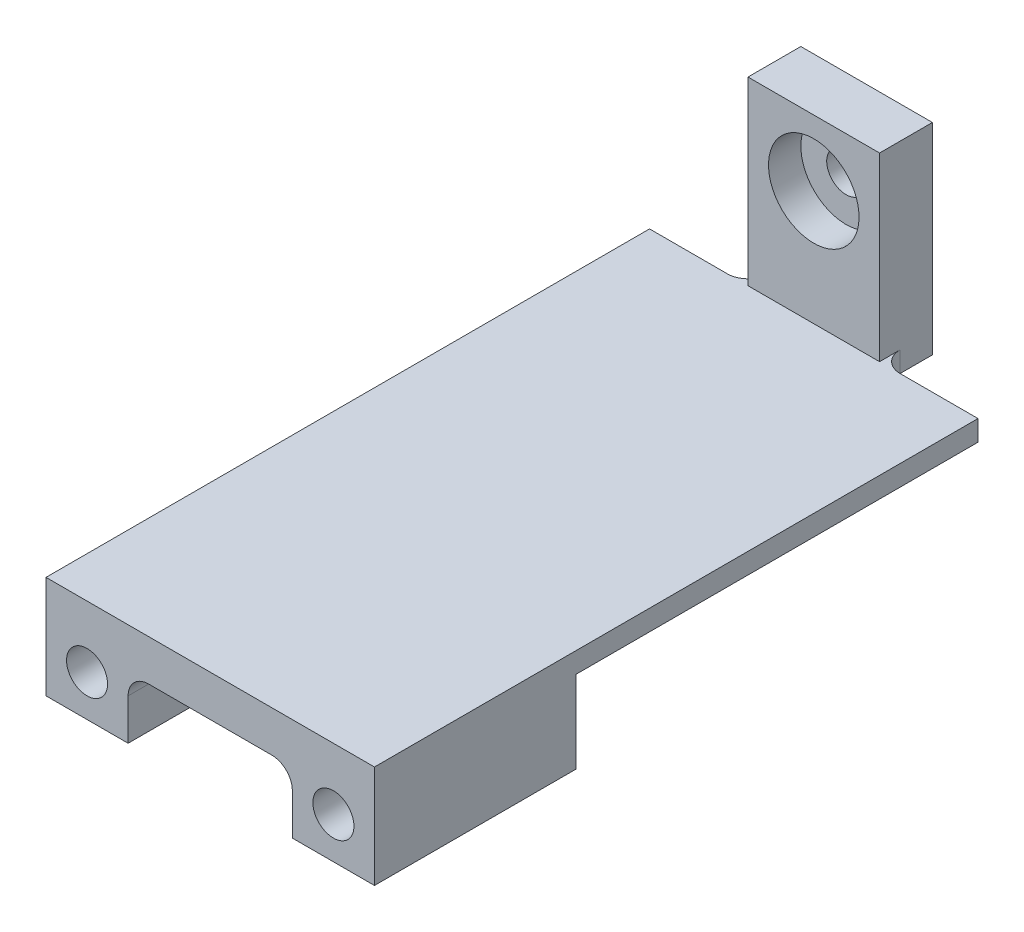
from build123d import *

# Parameters (mm, degrees)
SKETCH1_W               = 177.8
SKETCH1_H               = 101.6
BOSS_EXTRUDE1_DEPTH     = 12.7
SKETCH2_W               = 25.4
SKETCH2_H               = 19.05
BOSS_EXTRUDE2_DEPTH     = 101.6
SKETCH3_R               = 6.35
CUT_EXTRUDE1_DEPTH      = 101.6
SKETCH4_W               = 25.4
SKETCH4_H               = 19.05
BOSS_EXTRUDE3_DEPTH     = 101.6
SKETCH5_R               = 6.35
CUT_EXTRUDE2_DEPTH      = 101.6
SKETCH6_W               = 76.2
SKETCH6_H               = 31.75
CUT_EXTRUDE3_DEPTH      = 101.6
FILLET1_R               = 6.35
SKETCH8_W               = 101.6
SKETCH8_H               = 12.7
BOSS_EXTRUDE5_DEPTH     = 85.09
SKETCH9_W               = 40.7
SKETCH9_H               = 68.61
SKETCH9_R               = 6
BOSS_EXTRUDE6_DEPTH     = 16.35
SKETCH10_R              = 14
CUT_EXTRUDE4_DEPTH      = 10
FILLET2_R               = 6.35
SKETCH11_W              = 105.926535366
SKETCH11_H              = 109.219193109
CUT_EXTRUDE5_DEPTH      = 6.35
FILLET3_R               = 3.175
SKETCH12_W              = 101.6
SKETCH12_H              = 25.4
CUT_EXTRUDE6_DEPTH      = 3.175
CUT_EXTRUDE6_DEPTH_BACK = 39.25


with BuildPart() as part:
    # Sketch1 → Boss-Extrude1 (new body)
    with BuildSketch(Plane(origin=(0, 0, 0), x_dir=(1, 0, 0), z_dir=(0, 1, 0))):
        Rectangle(SKETCH1_W, SKETCH1_H)
    extrude(amount=BOSS_EXTRUDE1_DEPTH)

    # Sketch2 → Boss-Extrude2 (add)
    with BuildSketch(Plane.XY.offset(50.8)):
        with Locations((0, -9.525)):
            Rectangle(SKETCH2_W, SKETCH2_H)
    extrude(amount=-BOSS_EXTRUDE2_DEPTH)

    # Sketch3 → Cut-Extrude1 (cut)
    with BuildSketch(Plane.XY.offset(50.8)):
        with Locations((0, -6.35)):
            Circle(SKETCH3_R)
    extrude(amount=-CUT_EXTRUDE1_DEPTH, mode=Mode.SUBTRACT)

    # Sketch4 → Boss-Extrude3 (add)
    with BuildSketch(Plane.XY.offset(50.8)):
        with Locations((-76.2, -9.525)):
            Rectangle(SKETCH4_W, SKETCH4_H)
    boss_extrude3 = extrude(amount=-BOSS_EXTRUDE3_DEPTH)

    # Mirror1: Boss-Extrude3 across plane
    add(boss_extrude3.mirror(Plane(origin=(0, 0, 0), x_dir=(0, 0, 1), z_dir=(1, 0, 0))))

    # Sketch5 → Cut-Extrude2 (cut)
    with BuildSketch(Plane.XY.offset(50.8)):
        with Locations((-76.2, -6.35)):
            Circle(SKETCH5_R)
        with Locations((76.2, -6.35)):
            Circle(SKETCH5_R)
    extrude(amount=-CUT_EXTRUDE2_DEPTH, mode=Mode.SUBTRACT)

    # Sketch6 → Cut-Extrude3 (cut)
    with BuildSketch(Plane(origin=(0, 0, -50.8), x_dir=(-1, 0, 0), z_dir=(0, 0, -1))):
        with Locations((50.8, -3.175)):
            Rectangle(SKETCH6_W, SKETCH6_H)
    extrude(amount=-CUT_EXTRUDE3_DEPTH, mode=Mode.SUBTRACT)

    # Fillet1
    fillet1_edges = [part.edges().sort_by_distance(p)[0] for p in [
        (12.7, 0, 0),
        (63.5, 0, 0),
    ]]
    fillet(fillet1_edges, radius=FILLET1_R)

    # Sketch8 → Boss-Extrude5 (add)
    with BuildSketch(Plane(origin=(0, 0, -50.8), x_dir=(-1, 0, 0), z_dir=(0, 0, -1))):
        with Locations((-38.1, 6.35)):
            Rectangle(SKETCH8_W, SKETCH8_H)
    extrude(amount=BOSS_EXTRUDE5_DEPTH)

    # Sketch9 → Boss-Extrude6 (add)
    with BuildSketch(Plane(origin=(0, 0, -135.89), x_dir=(-1, 0, 0), z_dir=(0, 0, -1))):
        with Locations((-38.1, 34.305)):
            Rectangle(SKETCH9_W, SKETCH9_H)
        with Locations((-38.1, 48.26)):
            Circle(SKETCH9_R, mode=Mode.SUBTRACT)
    extrude(amount=BOSS_EXTRUDE6_DEPTH)

    # Sketch10 → Cut-Extrude4 (cut)
    with BuildSketch(Plane.XY.offset(-135.89)):
        with Locations((38.1, 48.26)):
            Circle(SKETCH10_R)
    extrude(amount=-CUT_EXTRUDE4_DEPTH, mode=Mode.SUBTRACT)

    # Fillet2
    fillet2_edges = [part.edges().sort_by_distance(p)[0] for p in [
        (58.45, 6.35, -135.89),
        (17.75, 6.35, -135.89),
    ]]
    fillet(fillet2_edges, radius=FILLET2_R)

    # Sketch11 → Cut-Extrude5 (cut)
    with BuildSketch(Plane.XZ):
        with Locations((35.936732317, -105.409596555)):
            Rectangle(SKETCH11_W, SKETCH11_H)
    extrude(amount=-CUT_EXTRUDE5_DEPTH, mode=Mode.SUBTRACT)

    # Fillet3
    fillet3_edges = [part.edges().sort_by_distance(p)[0] for p in [
        (38.1, 6.35, -50.8),
    ]]
    fillet(fillet3_edges, radius=FILLET3_R)

    # Sketch12 → Cut-Extrude6 (cut, two sides)
    with BuildSketch(Plane(origin=(0, 0, -50.8), x_dir=(-1, 0, 0), z_dir=(0, 0, -1))) as cut_extrude6_sk:
        with Locations((-38.1, -6.35)):
            Rectangle(SKETCH12_W, SKETCH12_H)
    extrude(amount=CUT_EXTRUDE6_DEPTH, mode=Mode.SUBTRACT)
    extrude(cut_extrude6_sk.sketch, amount=-CUT_EXTRUDE6_DEPTH_BACK, mode=Mode.SUBTRACT)


solid = part.part
